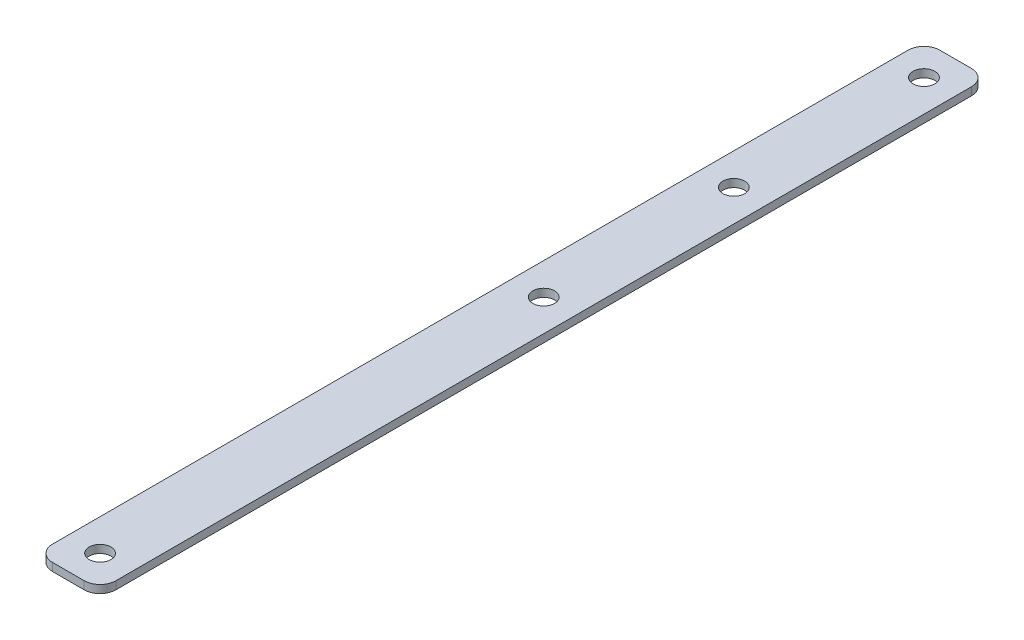
from build123d import *

# Parameters (mm, degrees)
SKETCH1_R           = 2.1828125
BOSS_EXTRUDE1_DEPTH = 1.5875


with BuildPart() as part:
    # Sketch1 → Boss-Extrude1 (new body)
    with BuildSketch(Plane(origin=(0, 0, 0), x_dir=(1, 0, 0), z_dir=(0, 1, 0))):
        with BuildLine():
            Line((3.175, 0), (9.525, 0))
            ThreePointArc((9.525, 0), (11.77006403, 0.92993597), (12.7, 3.175))
            Line((12.7, 3.175), (12.7, 174.625))
            ThreePointArc((12.7, 174.625), (11.77006403, 176.87006403), (9.525, 177.8))
            Line((9.525, 177.8), (3.175, 177.8))
            ThreePointArc((3.175, 177.8), (0.92993597, 176.87006403), (0, 174.625))
            Line((0, 174.625), (0, 3.175))
            ThreePointArc((0, 3.175), (0.92993597, 0.92993597), (3.175, 0))
        make_face()
        with Locations((6.35, 171.45)):
            Circle(SKETCH1_R, mode=Mode.SUBTRACT)
        with Locations((6.35, 6.35)):
            Circle(SKETCH1_R, mode=Mode.SUBTRACT)
        with Locations((6.35, 133.35)):
            Circle(SKETCH1_R, mode=Mode.SUBTRACT)
        with Locations((6.35, 95.25)):
            Circle(SKETCH1_R, mode=Mode.SUBTRACT)
    extrude(amount=BOSS_EXTRUDE1_DEPTH)


solid = part.part
